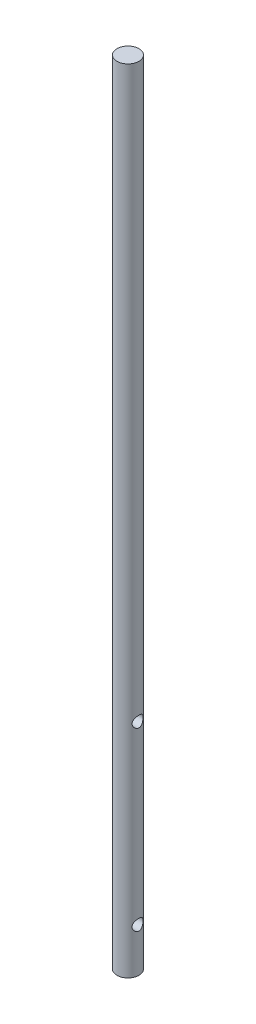
from build123d import *

# Parameters (mm, degrees)
SKETCH1_R               = 6.35
BOSS_EXTRUDE1_DEPTH     = 457.2
SKETCH2_R               = 3.175
CUT_EXTRUDE1_DEPTH      = 7.35
CUT_EXTRUDE1_DEPTH_BACK = 7.35


with BuildPart() as part:
    # Sketch1 → Boss-Extrude1 (new body)
    with BuildSketch(Plane(origin=(0, 0, 0), x_dir=(1, 0, 0), z_dir=(0, 1, 0))):
        with Locations(Location((0, 0, 0), (0, 0, 270))):  # turned: the seam where the file's is
            Circle(SKETCH1_R)
    extrude(amount=BOSS_EXTRUDE1_DEPTH)

    # Sketch2 → Cut-Extrude1 (cut, two sides)
    with BuildSketch(Plane(origin=(0, 0, 0), x_dir=(0, 0, -1), z_dir=(1, 0, 0))) as cut_extrude1_sk:
        with Locations((0, 25.4)):
            Circle(SKETCH2_R)
        with Locations((0, 127)):
            Circle(SKETCH2_R)
    extrude(amount=CUT_EXTRUDE1_DEPTH, mode=Mode.SUBTRACT)
    extrude(cut_extrude1_sk.sketch, amount=-CUT_EXTRUDE1_DEPTH_BACK, mode=Mode.SUBTRACT)


solid = part.part
